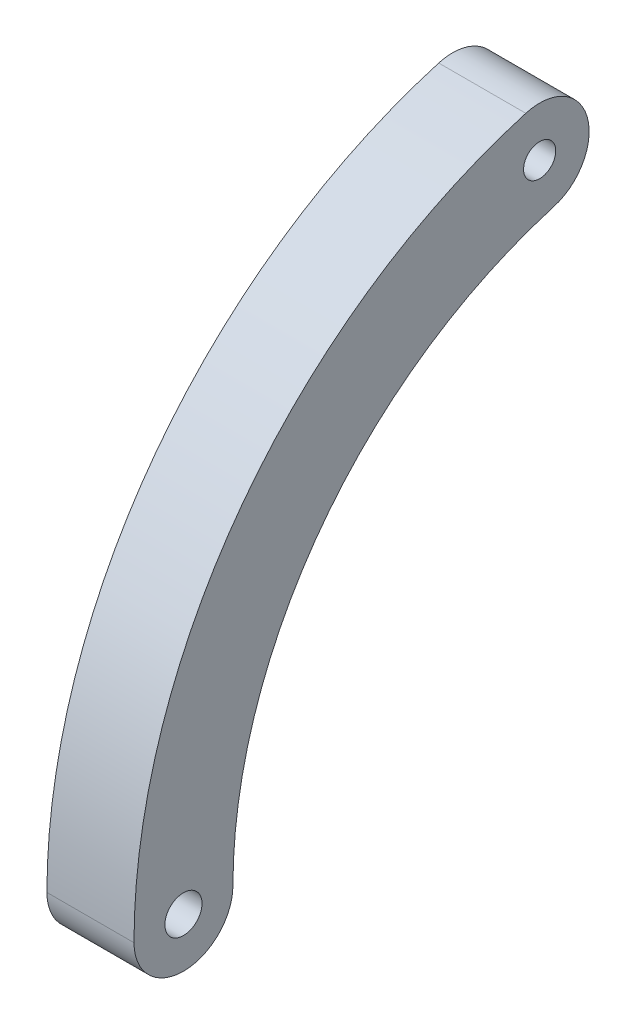
from build123d import *

# Parameters (mm, degrees)
ESQUISSE1_R        = 1.190625
ESQUISSE1_R_2      = 1.031875
BOSS_EXTRU_1_DEPTH = 5.588


with BuildPart() as part:
    # Esquisse1 → Boss.-Extru.1 (new body)
    with BuildSketch(Plane(origin=(0, 0, 0), x_dir=(0, 0, -1), z_dir=(1, 0, 0))):
        with BuildLine():
            ThreePointArc((-28.575, 0), (-22.86, 17.145), (-8.001, 27.432))
            ThreePointArc((-8.001, 27.432), (-5.842, 31.369), (-9.779, 33.528))
            ThreePointArc((-9.779, 33.528), (-27.94, 20.955), (-34.925, 0))
            ThreePointArc((-34.925, 0), (-31.75, -3.175), (-28.575, 0))
        make_face()
        with Locations((-31.75, 0)):
            Circle(ESQUISSE1_R, mode=Mode.SUBTRACT)
        with Locations((-8.89, 30.48)):
            Circle(ESQUISSE1_R_2, mode=Mode.SUBTRACT)
    extrude(amount=BOSS_EXTRU_1_DEPTH)


solid = part.part
